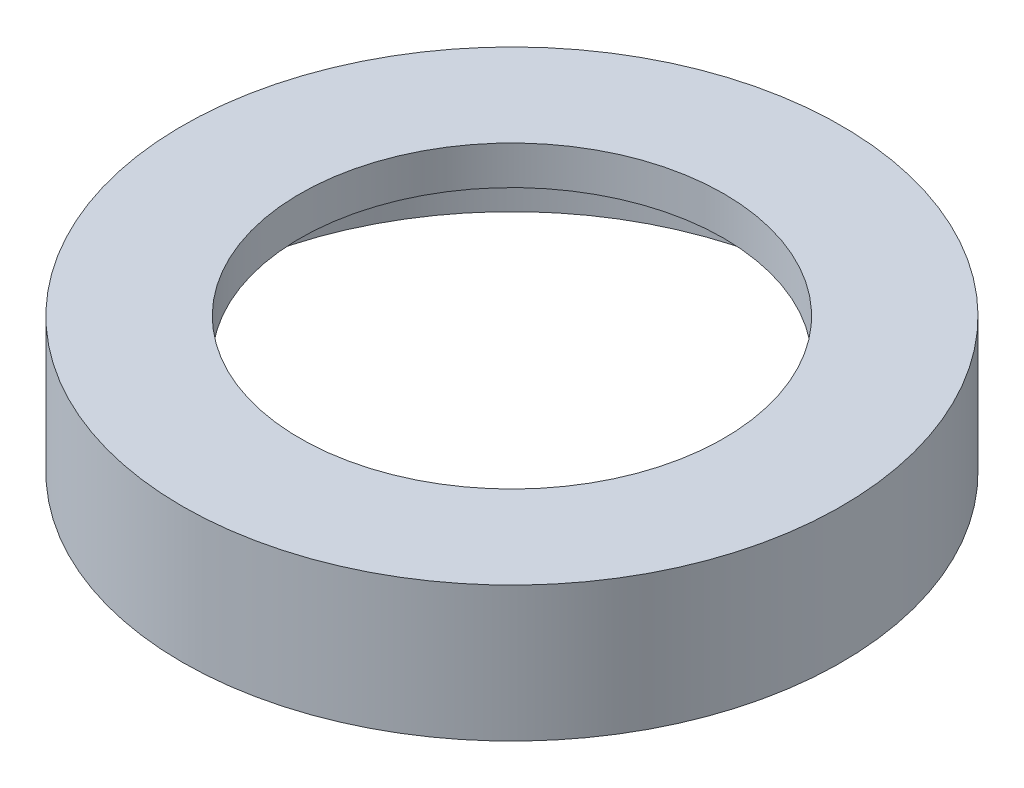
from build123d import *

# Parameters (mm, degrees)
CROQUIS1_R              = 17.074936514
SALIENTE_EXTRUIR2_DEPTH = 7
CROQUIS3_R              = 10.273489903
CORTAR_EXTRUIR1_DEPTH   = 4
CROQUIS4_R              = 11.220368527
CORTAR_EXTRUIR2_DEPTH   = 2
CROQUIS5_R              = 10.546758953
CORTAR_EXTRUIR4_DEPTH   = 8
CROQUIS6_R              = 16.523562211
CORTAR_EXTRUIR6_DEPTH   = 6
CROQUIS9_R              = 10.979364786
CROQUIS9_R_2            = 10.546758953
CORTAR_EXTRUIR8_DEPTH   = 1
CROQUIS10_R             = 11.521476728
CROQUIS10_R_2           = 10.979364786
SALIENTE_EXTRUIR3_DEPTH = 1


with BuildPart() as part:
    # Croquis1 → Saliente-Extruir2 (new body)
    with BuildSketch(Plane(origin=(0, 0, 0), x_dir=(1, 0, 0), z_dir=(0, 1, 0))):
        Circle(CROQUIS1_R)
    extrude(amount=SALIENTE_EXTRUIR2_DEPTH)

    # Croquis3 → Cortar-Extruir1 (cut)
    with BuildSketch(Plane(origin=(0, 7, 0), x_dir=(1, 0, 0), z_dir=(0, 1, 0))):
        Circle(CROQUIS3_R)
    extrude(amount=-CORTAR_EXTRUIR1_DEPTH, mode=Mode.SUBTRACT)

    # Croquis4 → Cortar-Extruir2 (cut)
    with BuildSketch(Plane(origin=(0, 0, 0), x_dir=(1, 0, 0), z_dir=(0, 1, 0))):
        Circle(CROQUIS4_R)
    extrude(amount=CORTAR_EXTRUIR2_DEPTH, mode=Mode.SUBTRACT)

    # Croquis5 → Cortar-Extruir4 (cut, through all)
    with BuildSketch(Plane(origin=(0, 0, 0), x_dir=(1, 0, 0), z_dir=(0, 1, 0))):
        Circle(CROQUIS5_R)
    extrude(amount=CORTAR_EXTRUIR4_DEPTH, mode=Mode.SUBTRACT)

    # Croquis6 → Cortar-Extruir6 (cut)
    with BuildSketch(Plane.XZ):
        Circle(CROQUIS6_R)
    extrude(amount=-CORTAR_EXTRUIR6_DEPTH, mode=Mode.SUBTRACT)

    # Croquis9 → Cortar-Extruir8 (cut)
    with BuildSketch(Plane.XZ.offset(-6)):
        Circle(CROQUIS9_R)
        Circle(CROQUIS9_R_2, mode=Mode.SUBTRACT)
    extrude(amount=-CORTAR_EXTRUIR8_DEPTH, mode=Mode.SUBTRACT)

    # Croquis10 → Saliente-Extruir3 (add)
    with BuildSketch(Plane.XZ.offset(-6)):
        Circle(CROQUIS10_R)
        Circle(CROQUIS10_R_2, mode=Mode.SUBTRACT)
    extrude(amount=SALIENTE_EXTRUIR3_DEPTH)


solid = part.part
